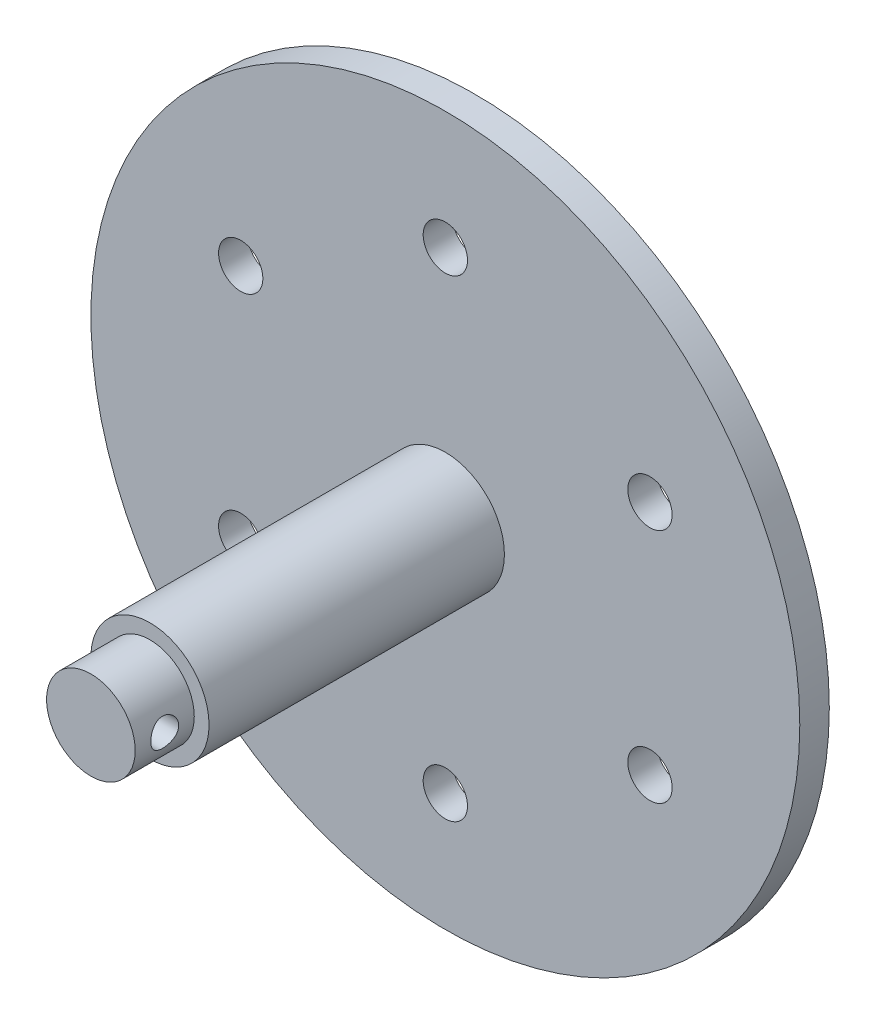
from build123d import *

# Parameters (mm, degrees)
SKETCH1_R           = 76.2
SKETCH1_R_2         = 4.7625
BOSS_EXTRUDE1_DEPTH = 6.35
SKETCH2_R           = 12.7
BOSS_EXTRUDE2_DEPTH = 76.2
SKETCH3_R           = 12.7
SKETCH3_R_2         = 9.525
CUT_EXTRUDE1_DEPTH  = 12.7
SKETCH4_R           = 3
CUT_EXTRUDE2_DEPTH  = 86.725


with BuildPart() as part:
    # Sketch1 → Boss-Extrude1 (new body)
    with BuildSketch(Plane.XY):
        Circle(SKETCH1_R)
        with Locations((0, 50.8)):
            Circle(SKETCH1_R_2, mode=Mode.SUBTRACT)
        with Locations((43.994090512, 25.4)):
            Circle(SKETCH1_R_2, mode=Mode.SUBTRACT)
        with Locations((43.994090512, -25.4)):
            Circle(SKETCH1_R_2, mode=Mode.SUBTRACT)
        with Locations((0, -50.8)):
            Circle(SKETCH1_R_2, mode=Mode.SUBTRACT)
        with Locations((-43.994090512, -25.4)):
            Circle(SKETCH1_R_2, mode=Mode.SUBTRACT)
        with Locations((-43.994090512, 25.4)):
            Circle(SKETCH1_R_2, mode=Mode.SUBTRACT)
    extrude(amount=BOSS_EXTRUDE1_DEPTH)

    # Sketch2 → Boss-Extrude2 (add)
    with BuildSketch(Plane.XY.offset(6.35)):
        Circle(SKETCH2_R)
    extrude(amount=BOSS_EXTRUDE2_DEPTH)

    # Sketch3 → Cut-Extrude1 (cut)
    with BuildSketch(Plane.XY.offset(82.55)):
        Circle(SKETCH3_R)
        Circle(SKETCH3_R_2, mode=Mode.SUBTRACT)
    extrude(amount=-CUT_EXTRUDE1_DEPTH, mode=Mode.SUBTRACT)

    # Sketch4 → Cut-Extrude2 (cut, through all)
    with BuildSketch(Plane(origin=(9.525, 0, 0), x_dir=(0, 0, -1), z_dir=(1, 0, 0))):
        with Locations((-76.2, 0)):
            Circle(SKETCH4_R)
    extrude(amount=-CUT_EXTRUDE2_DEPTH, mode=Mode.SUBTRACT)


solid = part.part
